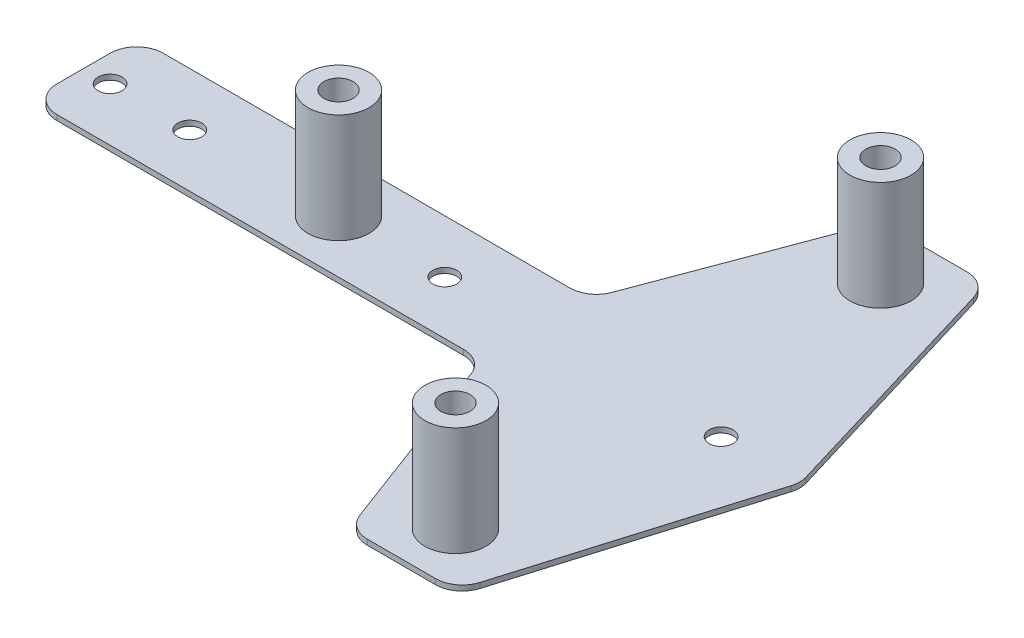
from build123d import *

# Parameters (mm, degrees)
BOSS_EXTRUDE1_DEPTH = 1
SKETCH2_R           = 2.75
CUT_EXTRUDE1_DEPTH  = 2
SKETCH3_R           = 5.75
SKETCH3_R_2         = 2.75
BOSS_EXTRUDE2_DEPTH = 20.5
SKETCH4_R           = 2.25
CUT_EXTRUDE2_DEPTH  = 2
SKETCH5_R           = 2.25
BOSS_EXTRUDE3_DEPTH = 1
SKETCH6_R           = 2.25
CUT_EXTRUDE3_DEPTH  = 2


with BuildPart() as part:
    # Sketch1 → Boss-Extrude1 (new body)
    with BuildSketch(Plane(origin=(0, 0, 0), x_dir=(1, 0, 0), z_dir=(0, 1, 0))):
        with BuildLine():
            Line((-55, 10), (6.534997659, 10))
            ThreePointArc((6.534997659, 10), (9.382971848, 10.890371912), (11.216643547, 13.244382792))
            Line((11.216643547, 13.244382792), (23.783356453, 46.755617208))
            ThreePointArc((23.783356453, 46.755617208), (25.617028152, 49.109628088), (28.465002341, 50))
            Line((28.465002341, 50), (41.279846746, 50))
            ThreePointArc((41.279846746, 50), (44.264499394, 49.011464641), (46.068978172, 46.436739428))
            Line((46.068978172, 46.436739428), (59.568978172, 1.436739428))
            ThreePointArc((59.568978172, 1.436739428), (59.779846746, 0), (59.568978172, -1.436739428))
            Line((59.568978172, -1.436739428), (46.068978172, -46.436739428))
            ThreePointArc((46.068978172, -46.436739428), (44.264499394, -49.011464641), (41.279846746, -50))
            Line((41.279846746, -50), (28.465002341, -50))
            ThreePointArc((28.465002341, -50), (25.617028152, -49.109628088), (23.783356453, -46.755617208))
            Line((23.783356453, -46.755617208), (11.216643547, -13.244382792))
            ThreePointArc((11.216643547, -13.244382792), (9.382971848, -10.890371912), (6.534997659, -10))
            Line((6.534997659, -10), (-55, -10))
            ThreePointArc((-55, -10), (-58.535533906, -8.535533906), (-60, -5))
            Line((-60, -5), (-60, 5))
            ThreePointArc((-60, 5), (-58.535533906, 8.535533906), (-55, 10))
        make_face()
    extrude(amount=BOSS_EXTRUDE1_DEPTH)

    # Sketch2 → Cut-Extrude1 (cut, through all)
    with BuildSketch(Plane(origin=(0, 1, 0), x_dir=(1, 0, 0), z_dir=(0, 1, 0))):
        with Locations((-27, 0)):
            Circle(SKETCH2_R)
        with Locations((35, 40)):
            Circle(SKETCH2_R)
        with Locations((35, -40)):
            Circle(SKETCH2_R)
    extrude(amount=-CUT_EXTRUDE1_DEPTH, mode=Mode.SUBTRACT)

    # Sketch3 → Boss-Extrude2 (add)
    with BuildSketch(Plane(origin=(0, 1, 0), x_dir=(1, 0, 0), z_dir=(0, 1, 0))):
        with Locations((-27, 0)):
            Circle(SKETCH3_R)
        with Locations((-27, 0)):
            Circle(SKETCH3_R_2, mode=Mode.SUBTRACT)
        with Locations((35, 40)):
            Circle(SKETCH3_R)
        with Locations((35, 40)):
            Circle(SKETCH3_R_2, mode=Mode.SUBTRACT)
        with Locations((35, -40)):
            Circle(SKETCH3_R)
        with Locations((35, -40)):
            Circle(SKETCH3_R_2, mode=Mode.SUBTRACT)
    extrude(amount=BOSS_EXTRUDE2_DEPTH)

    # Sketch4 → Cut-Extrude2 (cut, through all)
    with BuildSketch(Plane(origin=(0, 1, 0), x_dir=(1, 0, 0), z_dir=(0, 1, 0))):
        with Locations((-55, 0)):
            Circle(SKETCH4_R)
        with Locations((45, 0)):
            Circle(SKETCH4_R)
        with Locations((-7, 0)):
            Circle(SKETCH4_R)
    extrude(amount=-CUT_EXTRUDE2_DEPTH, mode=Mode.SUBTRACT)

    # Sketch5 → Boss-Extrude3 (add)
    with BuildSketch(Plane(origin=(0, 0, 0), x_dir=(1, 0, 0), z_dir=(0, 1, 0))):
        with BuildLine():
            Line((-55, 10), (-70, 10))
            ThreePointArc((-70, 10), (-73.535533906, 8.535533906), (-75, 5))
            Line((-75, 5), (-75, -5))
            ThreePointArc((-75, -5), (-73.535533906, -8.535533906), (-70, -10))
            Line((-70, -10), (-55, -10))
            Line((-55, -10), (-55, 10))
        make_face()
        with Locations((-70, 0)):
            Circle(SKETCH5_R, mode=Mode.SUBTRACT)
    extrude(amount=BOSS_EXTRUDE3_DEPTH)

    # Sketch6 → Cut-Extrude3 (cut, through all)
    with BuildSketch(Plane(origin=(0, 1, 0), x_dir=(1, 0, 0), z_dir=(0, 1, 0))):
        with Locations((-55, 0)):
            Circle(SKETCH6_R)
    extrude(amount=-CUT_EXTRUDE3_DEPTH, mode=Mode.SUBTRACT)


solid = part.part
